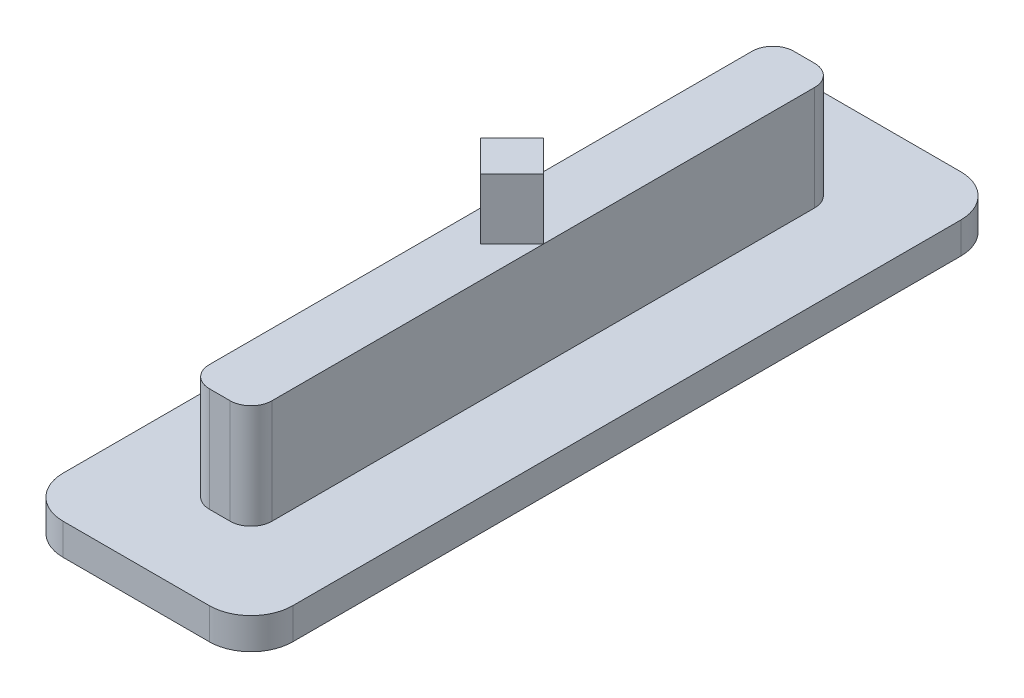
from build123d import *

# Parameters (mm, degrees)
SKETCH_1_W      = 3
SKETCH_1_H      = 28
EXTRUDE_1_DEPTH = 5
SKETCH_2_W      = 11
SKETCH_2_H      = 36
EXTRUDE_2_DEPTH = 1.5
FILLET_1_R      = 1
FILLET_3_R      = 2
EXTRUDE_3_DEPTH = 2.9


with BuildPart() as part:
    # Эскиз1 → Бобышка-Вытянуть1 (new body)
    with BuildSketch(Plane(origin=(0, 0, 0), x_dir=(1, 0, 0), z_dir=(0, 1, 0))):
        Rectangle(SKETCH_1_W, SKETCH_1_H)
    extrude(amount=EXTRUDE_1_DEPTH)

    # Эскиз2 → Бобышка-Вытянуть2 (add)
    with BuildSketch(Plane.XZ):
        Rectangle(SKETCH_2_W, SKETCH_2_H)
    extrude(amount=EXTRUDE_2_DEPTH)

    # Скругление1
    fillet_1_edges = [part.edges().sort_by_distance(p)[0] for p in [
        (-1.5, 2.5, -14),
        (1.5, 2.5, -14),
        (1.5, 2.5, 14),
        (-1.5, 2.5, 14),
    ]]
    fillet(fillet_1_edges, radius=FILLET_1_R)

    # Скругление3
    fillet_3_edges = [part.edges().sort_by_distance(p)[0] for p in [
        (5.5, -0.75, -18),
        (5.5, -0.75, 18),
        (-5.5, -0.75, 18),
        (-5.5, -0.75, -18),
    ]]
    fillet(fillet_3_edges, radius=FILLET_3_R)

    # Эскиз3 → Бобышка-Вытянуть3 (add)
    with BuildSketch(Plane(origin=(0, 5, 0), x_dir=(1, 0, 0), z_dir=(0, 1, 0))):
        Polygon((-1.5, 0), (0, 1.5), (1.5, 0), (0, -1.5), align=None)
    extrude(amount=EXTRUDE_3_DEPTH)


solid = part.part
